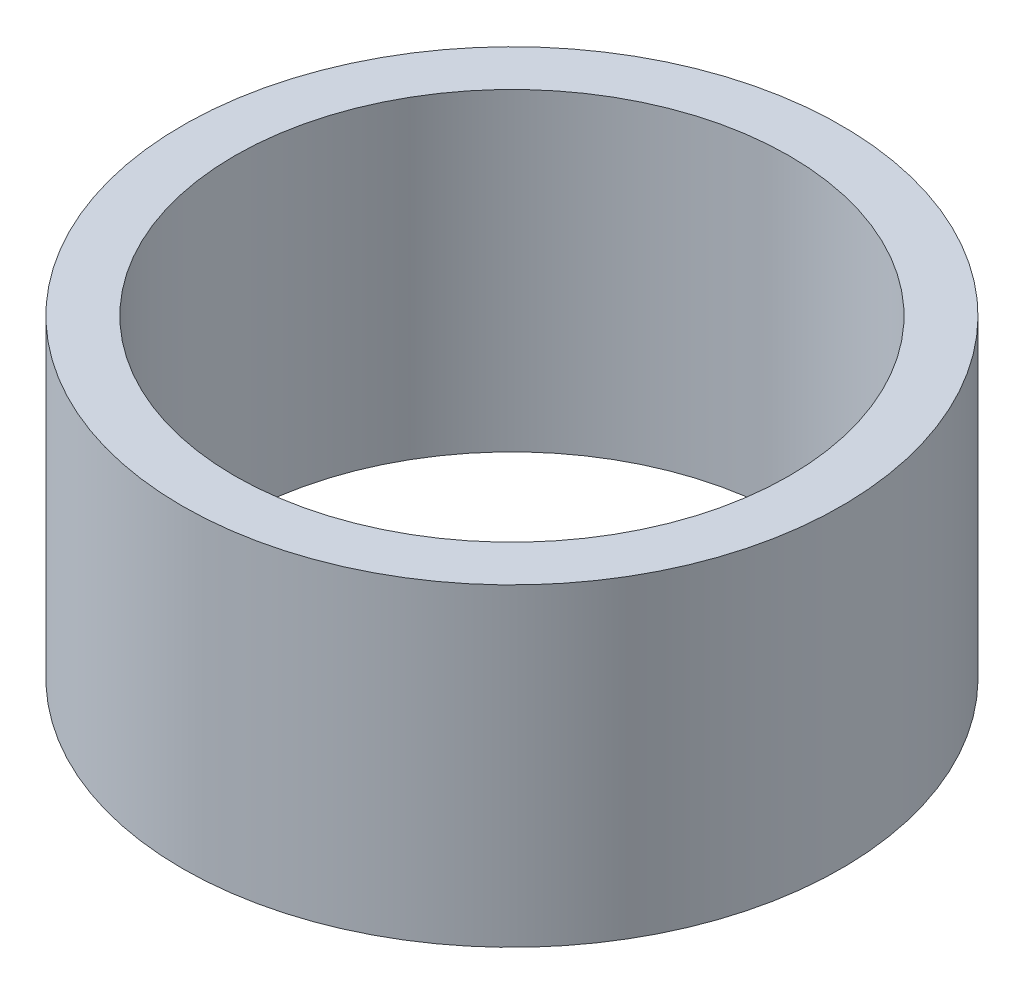
from build123d import *

# Parameters (mm, degrees)
SKETCH1_R           = 6.3
SKETCH1_R_2         = 5.3
BOSS_EXTRUDE1_DEPTH = 3


with BuildPart() as part:
    # Sketch1 → Boss-Extrude1 (new body, symmetric)
    with BuildSketch(Plane(origin=(0, 0, 0), x_dir=(1, 0, 0), z_dir=(0, 1, 0))):
        Circle(SKETCH1_R)
        Circle(SKETCH1_R_2, mode=Mode.SUBTRACT)
    extrude(amount=BOSS_EXTRUDE1_DEPTH, both=True)


solid = part.part
